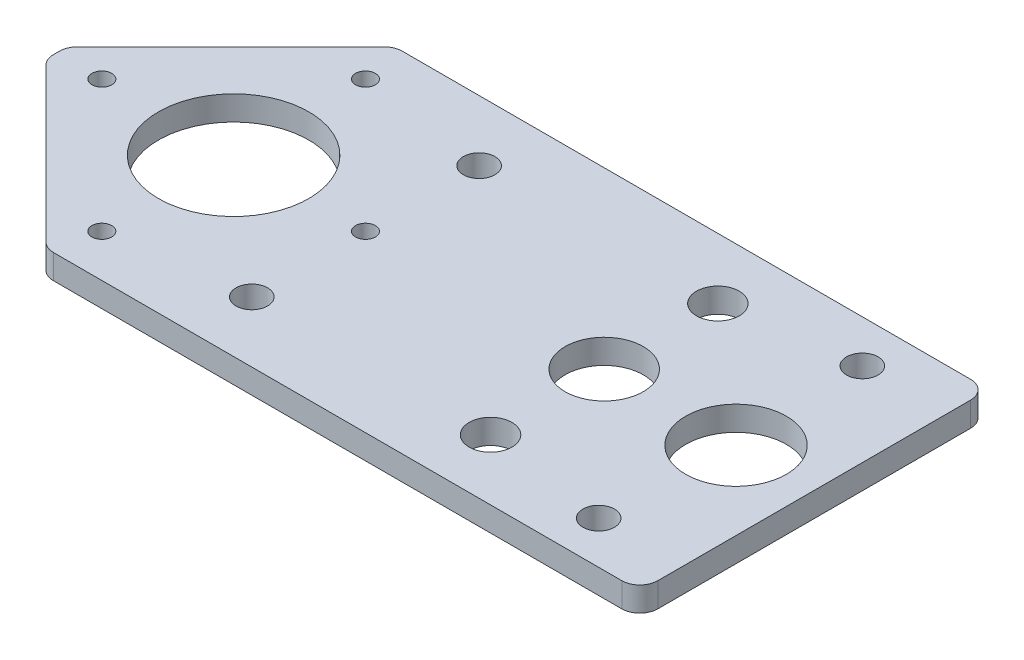
from build123d import *

# Parameters (mm, degrees)
SKETCH1_R           = 8.375
SKETCH1_R_2         = 3.56
SKETCH1_R_3         = 2.625
SKETCH1_R_4         = 12.5
SKETCH1_R_5         = 1.65
SKETCH1_R_6         = 6.5
BOSS_EXTRUDE1_DEPTH = 4.064


with BuildPart() as part:
    # Sketch1 → Boss-Extrude1 (new body)
    with BuildSketch(Plane.XZ):
        with BuildLine():
            Line((0, -26), (0, 26))
            ThreePointArc((0, 26), (-0.878679656, 28.121320344), (-3, 29))
            Line((-3, 29), (-97.5, 29))
            ThreePointArc((-97.5, 29), (-98.648050297, 28.771638598), (-99.621320344, 28.121320344))
            Line((-99.621320344, 28.121320344), (-125.121320344, 2.621320344))
            ThreePointArc((-125.121320344, 2.621320344), (-125.771638598, 1.648050297), (-126, 0.5))
            Line((-126, 0.5), (-126, -0.5))
            ThreePointArc((-126, -0.5), (-125.771638598, -1.648050297), (-125.121320344, -2.621320344))
            Line((-125.121320344, -2.621320344), (-99.621320344, -28.121320344))
            ThreePointArc((-99.621320344, -28.121320344), (-98.648050297, -28.771638598), (-97.5, -29))
            Line((-97.5, -29), (-3, -29))
            ThreePointArc((-3, -29), (-0.878679656, -28.121320344), (0, -26))
        make_face()
        with Locations((-13, 0)):
            Circle(SKETCH1_R, mode=Mode.SUBTRACT)
        with Locations((-34.92008574, 18.9)):
            Circle(SKETCH1_R_2, mode=Mode.SUBTRACT)
        with Locations((-74.62008574, 18.9)):
            Circle(SKETCH1_R_3, mode=Mode.SUBTRACT)
        with Locations((-34.92008574, -18.9)):
            Circle(SKETCH1_R_2, mode=Mode.SUBTRACT)
        with Locations((-74.62008574, -18.9)):
            Circle(SKETCH1_R_3, mode=Mode.SUBTRACT)
        with Locations((-96.540395956, 0)):
            Circle(SKETCH1_R_4, mode=Mode.SUBTRACT)
        with Locations((-74.62008574, 0)):
            Circle(SKETCH1_R_5, mode=Mode.SUBTRACT)
        with Locations((-118.460706173, 0)):
            Circle(SKETCH1_R_5, mode=Mode.SUBTRACT)
        with Locations((-96.540395956, -21.920310217)):
            Circle(SKETCH1_R_5, mode=Mode.SUBTRACT)
        with Locations((-96.540395956, 21.920310217)):
            Circle(SKETCH1_R_5, mode=Mode.SUBTRACT)
        with Locations((-13.92008574, 21.920310217)):
            Circle(SKETCH1_R_3, mode=Mode.SUBTRACT)
        with Locations((-13.92008574, -21.920310217)):
            Circle(SKETCH1_R_3, mode=Mode.SUBTRACT)
        with Locations((-34.92008574, 0)):
            Circle(SKETCH1_R_6, mode=Mode.SUBTRACT)
    extrude(amount=-BOSS_EXTRUDE1_DEPTH)


solid = part.part
